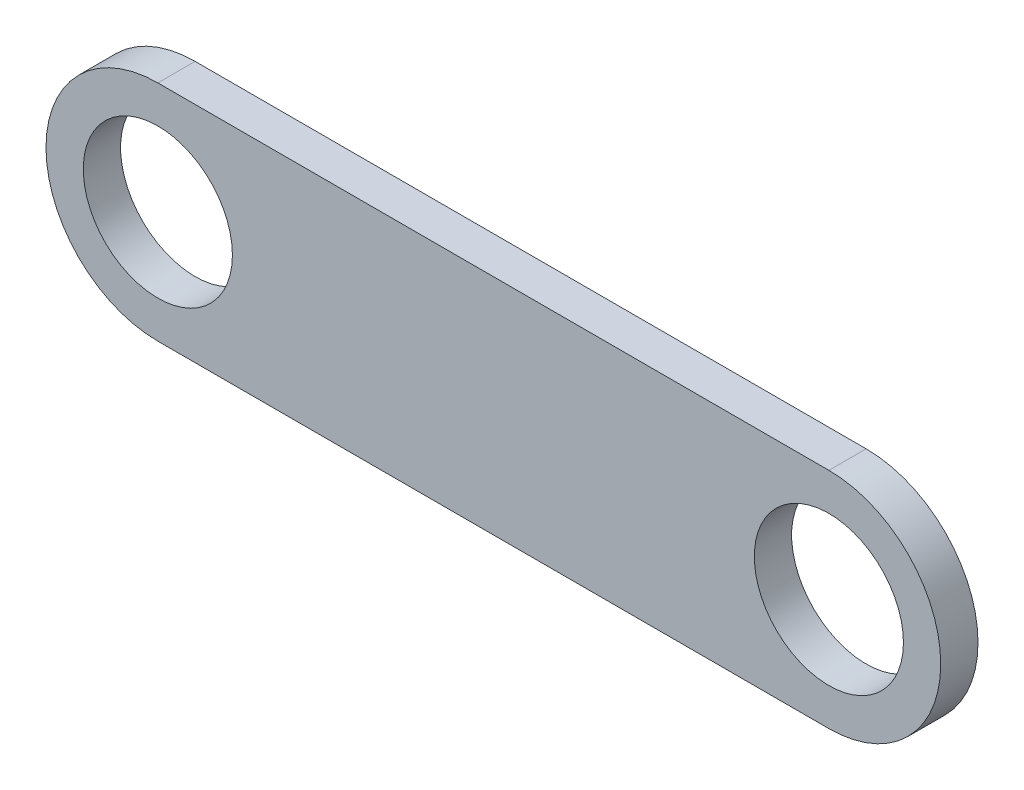
from build123d import *

# Parameters (mm, degrees)
CROQUIS1_R              = 10
SALIENTE_EXTRUIR1_DEPTH = 5


with BuildPart() as part:
    # Croquis1 → Saliente-Extruir1 (new body)
    with BuildSketch(Plane.XY):
        with BuildLine():
            Line((-27.04141276, 12.754010695), (62.95858724, 12.754010695))
            ThreePointArc((62.95858724, 12.754010695), (77.95858724, -2.245989305), (62.95858724, -17.245989305))
            Line((62.95858724, -17.245989305), (-27.04141276, -17.245989305))
            ThreePointArc((-27.04141276, -17.245989305), (-42.04141276, -2.245989305), (-27.04141276, 12.754010695))
        make_face()
        with Locations((-27.04141276, -2.245989305)):
            Circle(CROQUIS1_R, mode=Mode.SUBTRACT)
        with Locations((62.95858724, -2.245989305)):
            Circle(CROQUIS1_R, mode=Mode.SUBTRACT)
    extrude(amount=SALIENTE_EXTRUIR1_DEPTH)


solid = part.part
